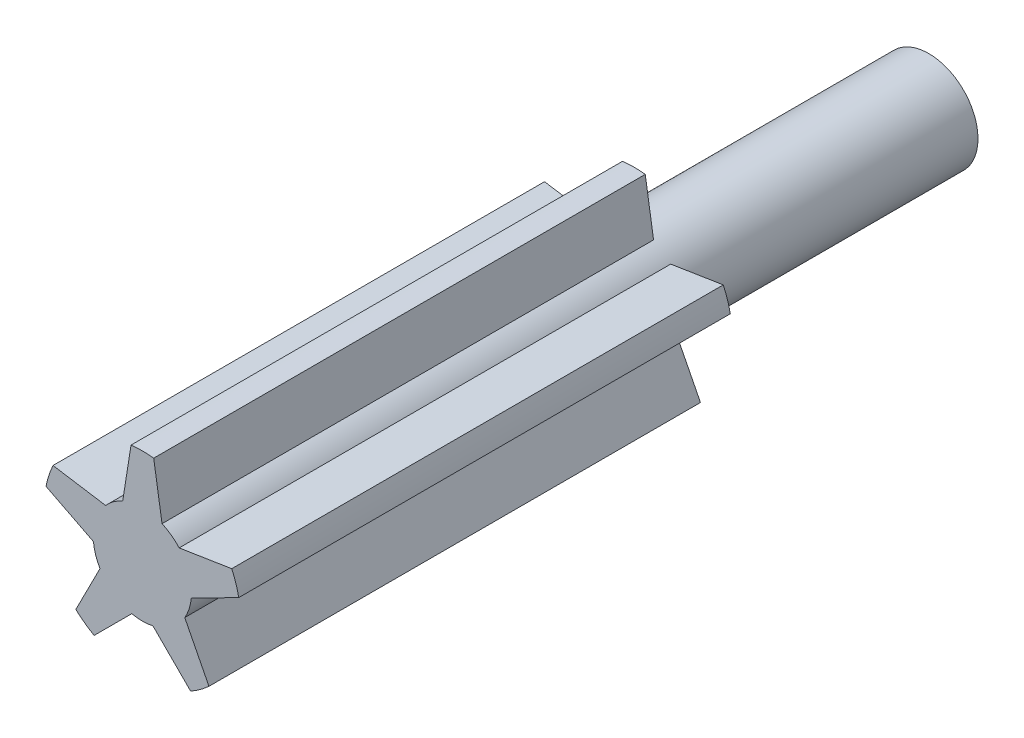
from build123d import *

# Parameters (mm, degrees)
SKETCH1_R           = 10
BOSS_EXTRUDE1_DEPTH = 30
BOSS_EXTRUDE2_DEPTH = 100


with BuildPart() as part:
    # Sketch1 → Boss-Extrude1 (new body, symmetric)
    with BuildSketch(Plane.XY):
        Circle(SKETCH1_R)
    extrude(amount=BOSS_EXTRUDE1_DEPTH, both=True)

    # Sketch2 → Boss-Extrude2 (add)
    with BuildSketch(Plane.XY.offset(30)):
        with BuildLine():
            ThreePointArc((2.305037087, 19.866726052), (0, 20), (-2.305037087, 19.866726052))
            Line((-2.305037087, 19.866726052), (-4, 9.16515139))
            ThreePointArc((-4, 9.16515139), (-5.877852523, 8.090169944), (-7.480508975, 6.636413601))
            Line((-7.480508975, 6.636413601), (-18.182083637, 8.331376514))
            ThreePointArc((-18.182083637, 8.331376514), (-19.021130326, 6.180339887), (-19.606674902, 3.946935431))
            Line((-19.606674902, 3.946935431), (-9.95264493, -0.97203853))
            ThreePointArc((-9.95264493, -0.97203853), (-9.510565163, -3.090169944), (-8.6232088, -5.063622221))
            Line((-8.6232088, -5.063622221), (-13.54218276, -14.717652193))
            ThreePointArc((-13.54218276, -14.717652193), (-11.755705046, -16.180339887), (-9.812554409, -17.427385804))
            Line((-9.812554409, -17.427385804), (-2.151072845, -9.76590424))
            ThreePointArc((-2.151072845, -9.76590424), (0, -10), (2.151072845, -9.76590424))
            Line((2.151072845, -9.76590424), (9.812554409, -17.427385804))
            ThreePointArc((9.812554409, -17.427385804), (11.755705046, -16.180339887), (13.54218276, -14.717652193))
            Line((13.54218276, -14.717652193), (8.6232088, -5.063622221))
            ThreePointArc((8.6232088, -5.063622221), (9.510565163, -3.090169944), (9.95264493, -0.97203853))
            Line((9.95264493, -0.97203853), (19.606674902, 3.946935431))
            ThreePointArc((19.606674902, 3.946935431), (19.021130326, 6.180339887), (18.182083637, 8.331376514))
            Line((18.182083637, 8.331376514), (7.480508975, 6.636413601))
            ThreePointArc((7.480508975, 6.636413601), (5.877852523, 8.090169944), (4, 9.16515139))
            Line((4, 9.16515139), (2.305037087, 19.866726052))
        make_face()
    extrude(amount=BOSS_EXTRUDE2_DEPTH)


solid = part.part
